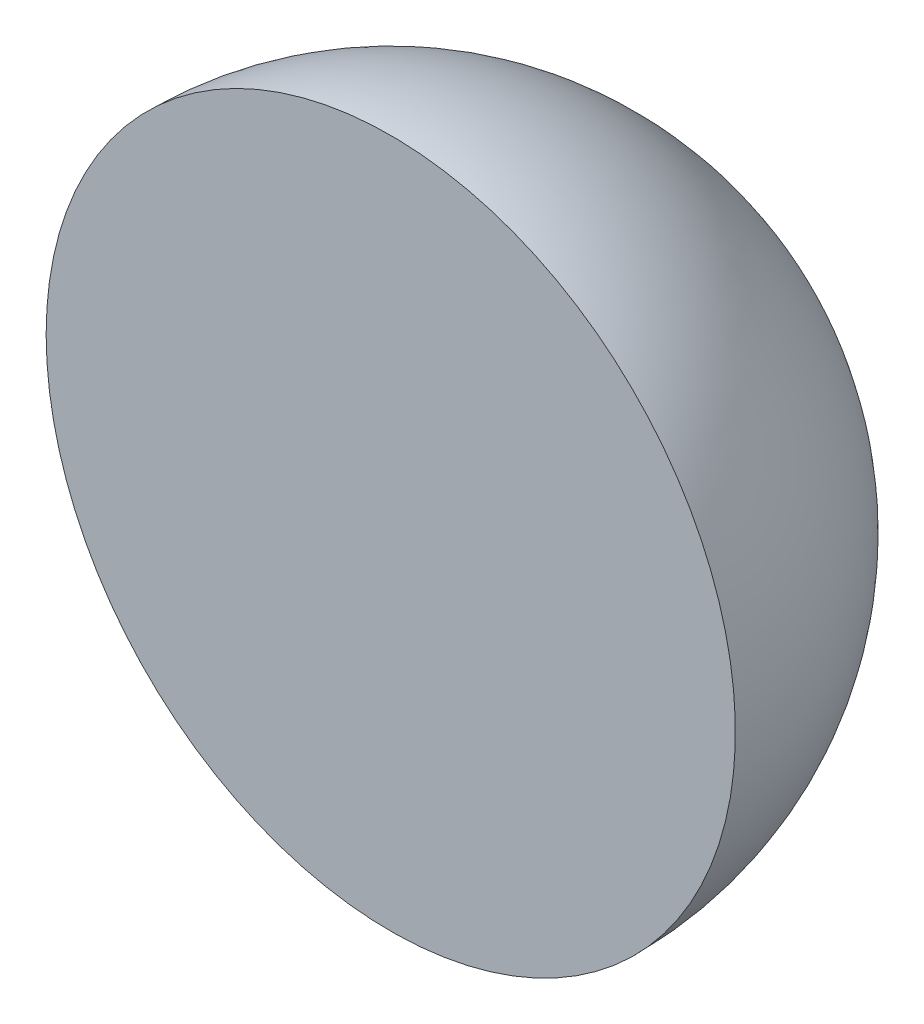
from build123d import *

# Parameters (mm, degrees)
REVOLVE5_ANGLE = 180


with BuildPart() as part:
    # Sketch1 → Revolve5 (revolve)
    with BuildSketch(Plane.XY):
        with BuildLine():
            Line((0, -62.5), (0, 62.5))
            ThreePointArc((0, 62.5), (62.5, 0), (0, -62.5))
        make_face()
    revolve(axis=Axis((0, -62.5, 0), (0, 1, 0)), revolution_arc=REVOLVE5_ANGLE)


solid = part.part
